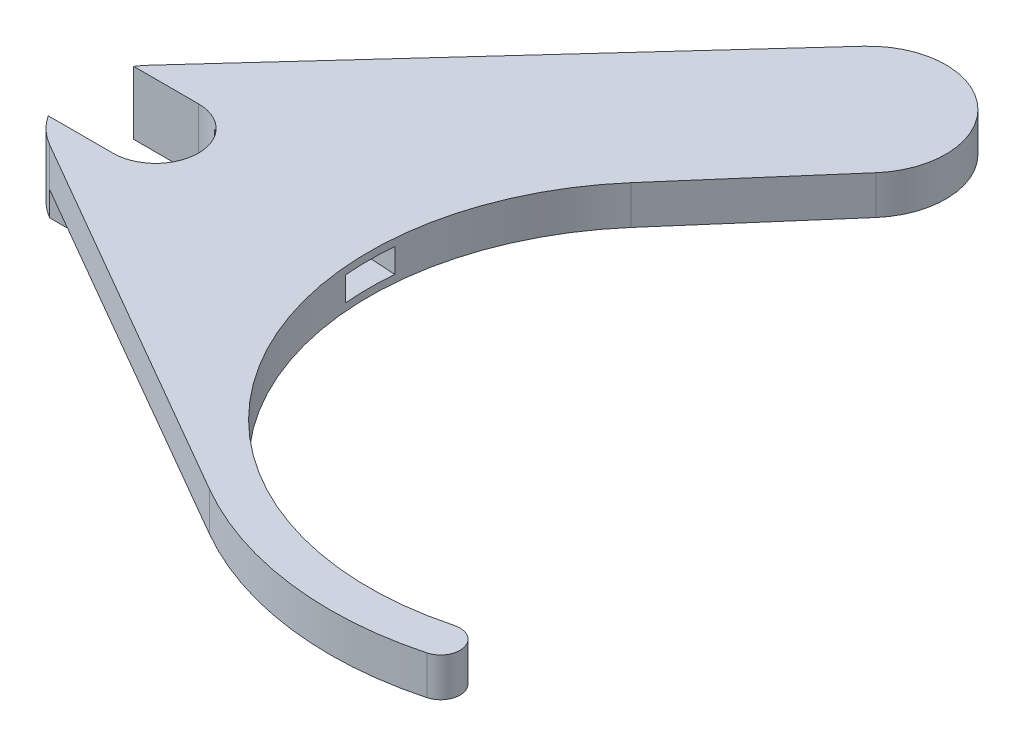
from build123d import *

# Parameters (mm, degrees)
BOSS_EXTRUDE1_DEPTH = 4.7625
SKETCH5_R           = 3.5000057
CUT_EXTRUDE2_DEPTH  = 3.37125
CUT_EXTRUDE3_DEPTH  = 1.98
SKETCH10_W          = 6.35
SKETCH10_H          = 0.79375
SKETCH10_W_2        = 35.745198541
SKETCH10_W_3        = 19.548012242
CUT_EXTRUDE4_DEPTH  = 63.97959256
CUT_EXTRUDE5_DEPTH  = 2.54
BOSS_EXTRUDE2_DEPTH = 2


with BuildPart() as part:
    # Sketch1 → Boss-Extrude1 (new body)
    with BuildSketch(Plane(origin=(0, 0, 0), x_dir=(1, 0, 0), z_dir=(0, 1, 0))):
        with BuildLine():
            ThreePointArc((47.438128512, -23.001108739), (21.083895316, -12.623567162), (23.295952901, 15.613744639))
            Line((23.295952901, 15.613744639), (32.606191406, 26.334377035))
            ThreePointArc((32.606191406, 26.334377035), (32.033289602, 35.241600739), (23.119772343, 34.776777479))
            Line((23.119772343, 34.776777479), (-4.692006503, 4.278735207))
            ThreePointArc((-4.692006503, 4.278735207), (-6.274930424, -0.973523588), (-3.175, -5.499261314))
            Line((-3.175, -5.499261314), (27.78125, -23.371860585))
            ThreePointArc((27.78125, -23.371860585), (37.752424387, -26.756618196), (48.25987898, -26.067923237))
            ThreePointArc((48.25987898, -26.067923237), (49.382410995, -24.123640754), (47.438128512, -23.001108739))
        make_face()
    extrude(amount=BOSS_EXTRUDE1_DEPTH)

    # Sketch5 → Cut-Extrude2 (cut)
    with BuildSketch(Plane.XZ):
        Circle(SKETCH5_R)
        with BuildLine():
            ThreePointArc((0, -3.5000057), (-3.5000057, 0), (0, 3.5000057))
            Line((0, 3.5000057), (-5.298345034, 3.5000057))
            ThreePointArc((-5.298345034, 3.5000057), (-6.35, 0), (-5.298345034, -3.5000057))
            Line((-5.298345034, -3.5000057), (0, -3.5000057))
        make_face()
    extrude(amount=-CUT_EXTRUDE2_DEPTH, mode=Mode.SUBTRACT)

    # Sketch6 → Cut-Extrude3 (cut)
    with BuildSketch(Plane.XZ.offset(-3.37125)):
        with BuildLine():
            Line((17.802786704, -2), (17.802786704, 2))
            Line((17.802786704, 2), (1.802786704, 3))
            ThreePointArc((1.802786704, 3), (3.5000057, 0), (1.802786704, -3))
            Line((1.802786704, -3), (17.802786704, -2))
        make_face()
    extrude(amount=CUT_EXTRUDE3_DEPTH, mode=Mode.SUBTRACT)

    # Sketch10 → Cut-Extrude4 (cut, through all)
    with BuildSketch(Plane(origin=(-3.175, 0, 5.499261314), x_dir=(0.866025404, 0, 0.5), z_dir=(-0.5, 0, 0.866025404))):
        with Locations((-3.175, 4.365625)):
            Rectangle(SKETCH10_W, SKETCH10_H)
        with Locations((17.872599271, 4.365625)):
            Rectangle(SKETCH10_W_2, SKETCH10_H)
        with Locations((45.519204662, 4.365625)):
            Rectangle(SKETCH10_W_3, SKETCH10_H)
        with Locations((45.519204662, 0.396875)):
            Rectangle(SKETCH10_W_3, SKETCH10_H)
        with Locations((17.872599271, 0.396875)):
            Rectangle(SKETCH10_W_2, SKETCH10_H)
        with Locations((-3.175, 0.396875)):
            Rectangle(SKETCH10_W, SKETCH10_H)
    extrude(amount=-CUT_EXTRUDE4_DEPTH, mode=Mode.SUBTRACT)

    # Sketch11 → Cut-Extrude5 (cut)
    with BuildSketch(Plane.XZ.offset(-3.37125)):
        with BuildLine():
            Line((-5.298345034, 3.5000057), (0, 3.5000057))
            ThreePointArc((0, 3.5000057), (3.5000057, 0), (0, -3.5000057))
            Line((0, -3.5000057), (-5.298345034, -3.5000057))
            ThreePointArc((-5.298345034, -3.5000057), (-6.35, 0), (-5.298345034, 3.5000057))
        make_face()
    extrude(amount=-CUT_EXTRUDE5_DEPTH, mode=Mode.SUBTRACT)

    # Sketch12 → Boss-Extrude2 (add)
    with BuildSketch(Plane.XZ.offset(-0.79375)):
        with BuildLine():
            Line((-3.175, 5.499261314), (-3.173710686, 5.5000057))
            Line((-3.173710686, 5.5000057), (0, 5.5000057))
            ThreePointArc((0, 5.5000057), (5.5000057, 0), (0, -5.5000057))
            Line((0, -5.5000057), (-3.57830535, -5.5000057))
            Line((-3.57830535, -5.5000057), (-4.692006503, -4.278735207))
            ThreePointArc((-4.692006503, -4.278735207), (-5.010327921, -3.901168303), (-5.298345034, -3.5000057))
            Line((-5.298345034, -3.5000057), (0, -3.5000057))
            ThreePointArc((0, -3.5000057), (3.5000057, 0), (0, 3.5000057))
            Line((0, 3.5000057), (-5.298345034, 3.5000057))
            ThreePointArc((-5.298345034, 3.5000057), (-4.353004683, 4.623186156), (-3.175, 5.499261314))
        make_face()
    extrude(amount=BOSS_EXTRUDE2_DEPTH)


solid = part.part
